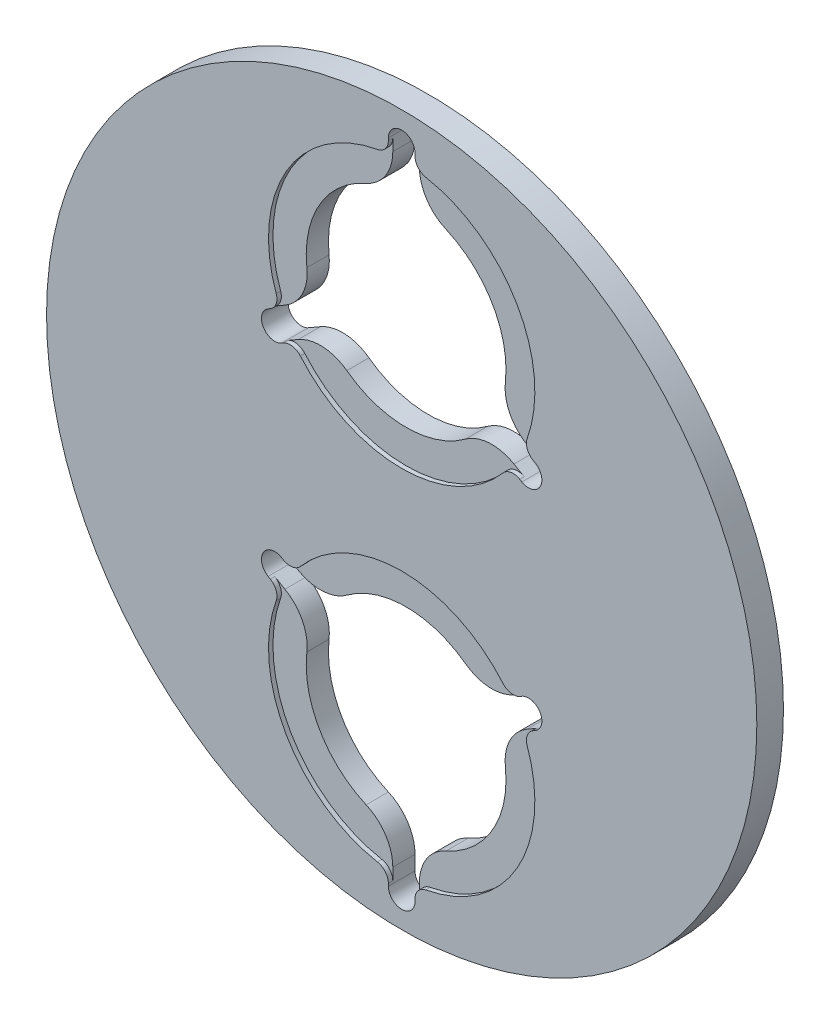
from build123d import *

# Parameters (mm, degrees)
SKETCH2_R                = 80
BOSS_EXTRUDE1_DEPTH      = 6
CUT_EXTRUDE2_DEPTH       = 6
SKETCH3_R                = 30
CUT_EXTRUDE3_DEPTH       = 1
FILLET1_R                = 3
FILLET2_R                = 10
CIRPATTERN1_COUNT        = 2
FILLET1_OF_CIRPATTERN1_R = 3
FILLET2_OF_CIRPATTERN1_R = 10


with BuildPart() as part:
    # Sketch2 → Boss-Extrude1 (new body)
    with BuildSketch(Plane.XY):
        Circle(SKETCH2_R)
    extrude(amount=BOSS_EXTRUDE1_DEPTH)

    # Sketch1 → Cut-Extrude2 (cut)
    with BuildSketch(Plane.XY):
        with BuildLine():
            ThreePointArc((3, 73), (0, 76), (-3, 73))
            Line((-3, 73), (-3, 62.299103121))
            ThreePointArc((-3, 62.299103121), (-19.485571585, 51.25), (-20.811589784, 31.448524651))
            Line((-20.811589784, 31.448524651), (-30.078838325, 26.098076211))
            ThreePointArc((-30.078838325, 26.098076211), (-31.176914536, 22), (-27.078838325, 20.901923789))
            Line((-27.078838325, 20.901923789), (-17.811589784, 26.252372228))
            ThreePointArc((-17.811589784, 26.252372228), (0, 17.5), (17.811589784, 26.252372228))
            Line((17.811589784, 26.252372228), (27.078838325, 20.901923789))
            ThreePointArc((27.078838325, 20.901923789), (31.176914536, 22), (30.078838325, 26.098076211))
            Line((30.078838325, 26.098076211), (20.811589784, 31.448524651))
            ThreePointArc((20.811589784, 31.448524651), (19.485571585, 51.25), (3, 62.299103121))
            Line((3, 62.299103121), (3, 73))
        make_face()
    cut_extrude2 = extrude(amount=CUT_EXTRUDE2_DEPTH, mode=Mode.SUBTRACT)

    # Sketch3 → Cut-Extrude3 (cut)
    with BuildSketch(Plane.XY.offset(6)):
        with Locations((0, 40)):
            Circle(SKETCH3_R)
    cut_extrude3 = extrude(amount=-CUT_EXTRUDE3_DEPTH, mode=Mode.SUBTRACT)

    # Fillet1
    fillet1_edges = [part.edges().sort_by_distance(p)[0] for p in [
        (24.350531909, 22.477112232, 5.5),
        (-24.350531909, 22.477112232, 5.5),
        (-27.350531909, 27.673264655, 5.5),
        (-3, 69.849623113, 5.5),
        (27.350531909, 27.673264655, 5.5),
        (3, 69.849623113, 5.5),
    ]]
    fillet(fillet1_edges, radius=FILLET1_R)

    # Fillet2
    fillet2_edges = [part.edges().sort_by_distance(p)[0] for p in [
        (-3, 62.299103121, 2.5),
        (-20.811589784, 31.448524651, 2.5),
        (-17.811589784, 26.252372228, 2.5),
        (17.811589784, 26.252372228, 2.5),
        (20.811589784, 31.448524651, 2.5),
        (3, 62.299103121, 2.5),
    ]]
    fillet(fillet2_edges, radius=FILLET2_R)

    # CirPattern1: Cut-Extrude2, Cut-Extrude3 ×2 about axis
    cirpattern1_axis = Axis((0, 0, 6), (0, 0, -1))
    add([cut_extrude2.rotate(cirpattern1_axis, i * 360 / CIRPATTERN1_COUNT) for i in range(1, CIRPATTERN1_COUNT)], mode=Mode.SUBTRACT)
    add([cut_extrude3.rotate(cirpattern1_axis, i * 360 / CIRPATTERN1_COUNT) for i in range(1, CIRPATTERN1_COUNT)], mode=Mode.SUBTRACT)

    # Fillet1 of CirPattern1
    fillet1_of_cirpattern1_edges = [part.edges().sort_by_distance(p)[0] for p in [
        (-24.350531909, -22.477112232, 5.5),
        (24.350531909, -22.477112232, 5.5),
        (27.350531909, -27.673264655, 5.5),
        (3, -69.849623113, 5.5),
        (-27.350531909, -27.673264655, 5.5),
        (-3, -69.849623113, 5.5),
    ]]
    fillet(fillet1_of_cirpattern1_edges, radius=FILLET1_OF_CIRPATTERN1_R)

    # Fillet2 of CirPattern1
    fillet2_of_cirpattern1_edges = [part.edges().sort_by_distance(p)[0] for p in [
        (3, -62.299103121, 2.5),
        (20.811589784, -31.448524651, 2.5),
        (17.811589784, -26.252372228, 2.5),
        (-17.811589784, -26.252372228, 2.5),
        (-20.811589784, -31.448524651, 2.5),
        (-3, -62.299103121, 2.5),
    ]]
    fillet(fillet2_of_cirpattern1_edges, radius=FILLET2_OF_CIRPATTERN1_R)


solid = part.part
